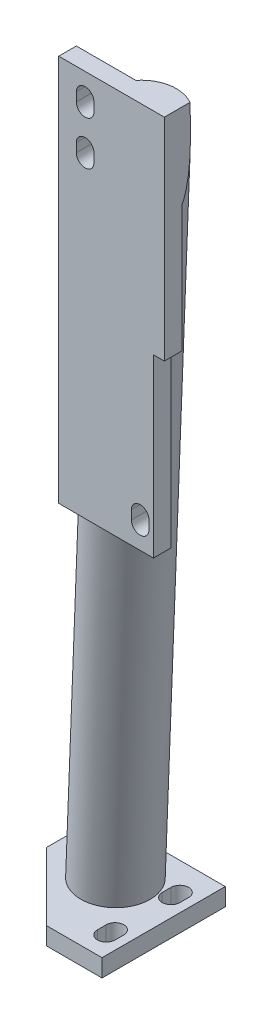
from build123d import *

# Parameters (mm, degrees)
SKETCH1_W                  = 88.9
SKETCH1_H                  = 88.9
EXTRUDE1_DEPTH             = 12.7
EXTRUDE2_DEPTH             = 127.363404513
EXTRUDE9_DEPTH             = 127.363404513
SKETCH4_W                  = 76.2
SKETCH4_H                  = 279.4
EXTRUDE3_DEPTH             = 12.7
EXTRUDE7_DEPTH             = 622.292826593
EXTRUDE6_REACH             = 742.115
EXTRUDE6_START             = 127
SKETCH7_R                  = 25.4
SKETCH7_R_2                = 12.7
EXTRUDE6_DIRECTION_2_REACH = 742.115
EXTRUDE10_DEPTH            = 676.899389977
SKETCH9_W                  = 7.874
SKETCH9_H                  = 127
EXTRUDE8_DEPTH             = 622.292826593


with BuildPart() as part:
    # Sketch1 → Extrude1 (new body)
    with BuildSketch(Plane(origin=(0, 0, 0), x_dir=(1, 0, 0), z_dir=(0, 1, 0))):
        with Locations((-44.45, 44.45)):
            Rectangle(SKETCH1_W, SKETCH1_H)
    extrude(amount=EXTRUDE1_DEPTH)

    # Sketch2 → Extrude2 (cut, through all)
    with BuildSketch(Plane(origin=(0, 12.7, 0), x_dir=(1, 0, 0), z_dir=(0, 1, 0))):
        with BuildLine():
            Line((-19.05, 15.748), (-19.05, 22.098))
            ThreePointArc((-19.05, 22.098), (-12.7, 28.448), (-6.35, 22.098))
            Line((-6.35, 22.098), (-6.35, 15.748))
            ThreePointArc((-6.35, 15.748), (-12.7, 9.398), (-19.05, 15.748))
        make_face()
        with BuildLine():
            Line((-19.05, 62.484), (-19.05, 68.834))
            ThreePointArc((-19.05, 68.834), (-12.7, 75.184), (-6.35, 68.834))
            Line((-6.35, 68.834), (-6.35, 62.484))
            ThreePointArc((-6.35, 62.484), (-12.7, 56.134), (-19.05, 62.484))
        make_face()
        with BuildLine():
            Line((-85.725, 68.834), (-85.725, 75.184))
            ThreePointArc((-85.725, 75.184), (-79.375, 81.534), (-73.025, 75.184))
            Line((-73.025, 75.184), (-73.025, 68.834))
            ThreePointArc((-73.025, 68.834), (-79.375, 62.484), (-85.725, 68.834))
        make_face()
    extrude(amount=-EXTRUDE2_DEPTH, mode=Mode.SUBTRACT)

    # Sketch10 → Extrude9 (cut, through all)
    with BuildSketch(Plane.XZ):
        Polygon((-88.9, -49.022), (-39.878, 0), (-88.9, 0), align=None)
    extrude(amount=-EXTRUDE9_DEPTH, mode=Mode.SUBTRACT)



with BuildPart() as body_2:
    # Sketch4 → Extrude3 (new body)
    with BuildSketch(Plane(origin=(0, 0, 42.926), x_dir=(-1, 0, 0), z_dir=(0, 0, -1))):
        with Locations((-49.784, 463.55)):
            Rectangle(SKETCH4_W, SKETCH4_H)
    extrude(amount=EXTRUDE3_DEPTH)

    # Sketch8 → Extrude7 (cut, through all)
    with BuildSketch(Plane(origin=(0, 0, 30.226), x_dir=(-1, 0, 0), z_dir=(0, 0, -1))):
        with BuildLine():
            Line((-24.384, 587.375), (-24.384, 581.025))
            ThreePointArc((-24.384, 581.025), (-30.734, 574.675), (-37.084, 581.025))
            Line((-37.084, 581.025), (-37.084, 587.375))
            ThreePointArc((-37.084, 587.375), (-30.734, 593.725), (-24.384, 587.375))
        make_face()
        with BuildLine():
            Line((-24.384, 555.625), (-24.384, 549.275))
            ThreePointArc((-24.384, 549.275), (-30.734, 542.925), (-37.084, 549.275))
            Line((-37.084, 549.275), (-37.084, 555.625))
            ThreePointArc((-37.084, 555.625), (-30.734, 561.975), (-24.384, 555.625))
        make_face()
        with BuildLine():
            Line((-64.0842, 346.075), (-64.0842, 339.725))
            ThreePointArc((-64.0842, 339.725), (-70.4342, 333.375), (-76.7842, 339.725))
            Line((-76.7842, 339.725), (-76.7842, 346.075))
            ThreePointArc((-76.7842, 346.075), (-70.4342, 352.425), (-64.0842, 346.075))
        make_face()
    extrude(amount=-EXTRUDE7_DEPTH, mode=Mode.SUBTRACT)


with BuildPart() as part_1:
    add(part.part)

    add(body_2.part)  # Extrude6 merges body 2
    # Extrude6: up to this plane
    extrude6_end = Plane(origin=(11.684, 323.85, 30.226), z_dir=(0, 0, 1))
    # Sketch7 → Extrude6 (add, up to the surface)
    with BuildSketch(Plane(origin=(-44.958, 12.7, -54.61), x_dir=(-0.9783852357673664, 0.18254912655536365, 0.09715012519965675), z_dir=(0.1967453547942853, 0.9663814656142476, 0.16552379975136336)).offset(EXTRUDE6_START), mode=Mode.PRIVATE) as extrude6_sk1:
        with Locations(Location((0, 0, 0), (0, 0, 189.444307403))):
            Circle(SKETCH7_R)
        with Locations(Location((0, 0, 0), (0, 0, 84.346682726))):
            Circle(SKETCH7_R_2, mode=Mode.SUBTRACT)
    extrude6_tool1 = split(extrude(extrude6_sk1.sketch, amount=EXTRUDE6_REACH, mode=Mode.PRIVATE), bisect_by=extrude6_end, keep=Keep.BOTH, mode=Mode.PRIVATE)
    add(extrude6_tool1.solids().sort_by_distance((-43.534266, 139.141689, -27.248481))[0])

    # Extrude6 direction 2: up to this plane
    extrude6_direction_2_end = Plane(origin=(0, 12.7, -88.9), z_dir=(0, 1, 0))
    # Sketch7 → Extrude6 direction 2 (add, up to the surface)
    with BuildSketch(Plane(origin=(-44.958, 12.7, -54.61), x_dir=(-0.9783852357673664, 0.18254912655536365, 0.09715012519965675), z_dir=(0.1967453547942853, 0.9663814656142476, 0.16552379975136336)).offset(EXTRUDE6_START), mode=Mode.PRIVATE) as extrude6_direction_2_sk1:
        with Locations(Location((0, 0, 0), (0, 0, 189.444307403))):
            Circle(SKETCH7_R)
        with Locations(Location((0, 0, 0), (0, 0, 84.346682726))):
            Circle(SKETCH7_R_2, mode=Mode.SUBTRACT)
    extrude6_direction_2_tool1 = split(extrude(extrude6_direction_2_sk1.sketch, amount=-EXTRUDE6_DIRECTION_2_REACH, mode=Mode.PRIVATE), bisect_by=extrude6_direction_2_end, keep=Keep.BOTH, mode=Mode.PRIVATE)
    add(extrude6_direction_2_tool1.solids().sort_by_distance((-43.534266, 139.141689, -27.248481))[0])

    # Sketch11 → Extrude10 (cut, through all)
    with BuildSketch(Plane.XY.offset(30.226)):
        with BuildLine():
            Line((54.665648122, 603.25), (87.884, 603.25))
            Line((87.884, 603.25), (87.884, 542.273095972))
            add(Edge.make_bspline(
                [(87.884, 542.273095972), (134.728854914, 839.694203258), (54.665648122, 603.25)],
                knots=[1.834299587, 1.834299587, 1.834299587, 4.060538938, 4.060538938, 4.060538938], degree=2, weights=[1, 0.441865068, 1]))
        make_face()
    extrude(amount=-EXTRUDE10_DEPTH, mode=Mode.SUBTRACT)

    # Sketch9 → Extrude8 (cut, through all)
    with BuildSketch(Plane(origin=(0, 0, 30.226), x_dir=(-1, 0, 0), z_dir=(0, 0, -1))):
        with Locations((-83.947, 387.35)):
            Rectangle(SKETCH9_W, SKETCH9_H)
    extrude(amount=-EXTRUDE8_DEPTH, mode=Mode.SUBTRACT)


solid = part_1.part
